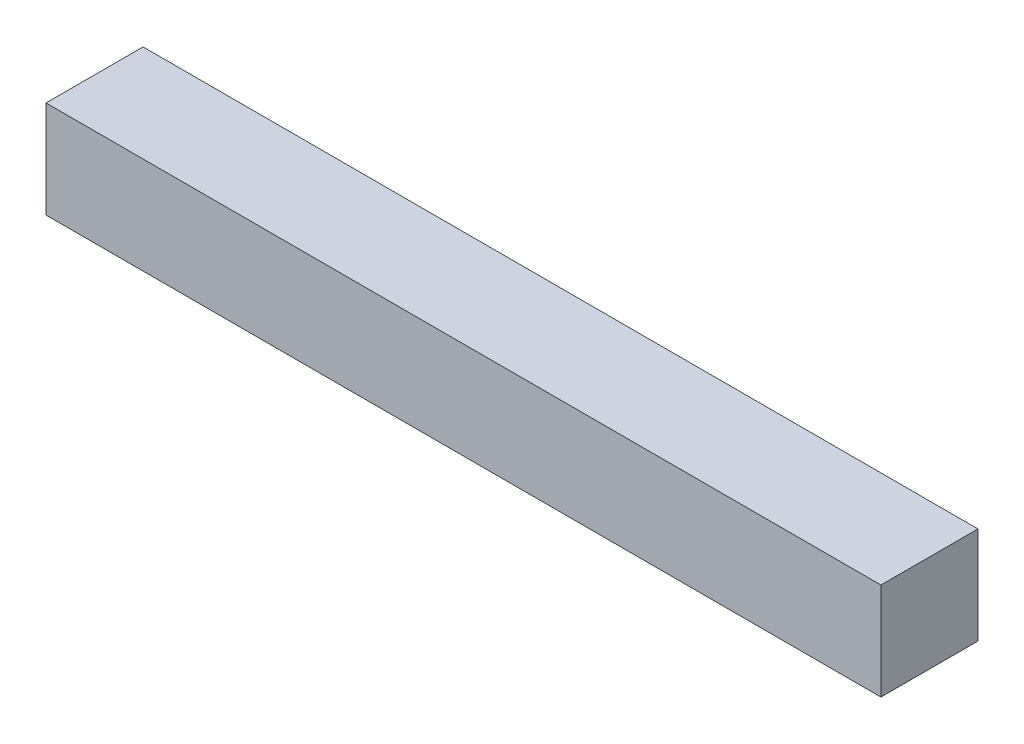
from build123d import *

# Parameters (mm, degrees)
SKETCH1_W           = 10
SKETCH1_H           = 10
BOSS_EXTRUDE1_DEPTH = 86


with BuildPart() as part:
    # Sketch1 → Boss-Extrude1 (new body)
    with BuildSketch(Plane(origin=(0, 0, 0), x_dir=(0, 0, -1), z_dir=(1, 0, 0))):
        Rectangle(SKETCH1_W, SKETCH1_H)
    extrude(amount=BOSS_EXTRUDE1_DEPTH)


solid = part.part
